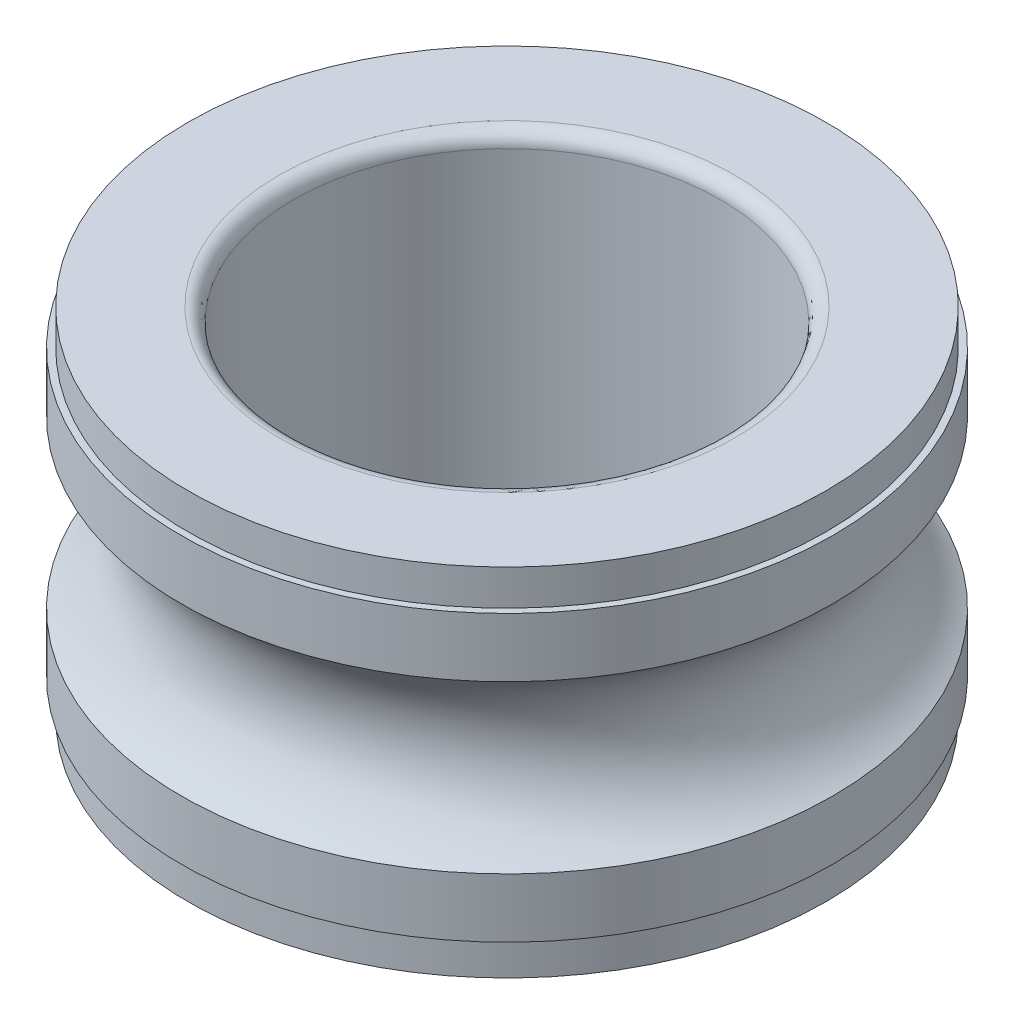
from build123d import *


with BuildPart() as part:
    # Sketch1 → Revolve1 (revolve)
    with BuildSketch(Plane(origin=(0, 0, 0), x_dir=(-1, 0, 0), z_dir=(0, 0, -1))):
        with BuildLine():
            Line((-4.575, -0.5), (-4.575, -1.330865705))
            ThreePointArc((-4.575, -1.330865705), (-3.9, -2.5), (-4.575, -3.669134295))
            Line((-4.575, -3.669134295), (-4.575, -4.5))
            Line((-4.575, -4.5), (-4.4835, -4.5))
            Line((-4.4835, -4.5), (-4.4835, -5))
            Line((-4.4835, -5), (-3.2, -5))
            ThreePointArc((-3.2, -5), (-3.058578644, -4.941421356), (-3, -4.8))
            Line((-3, -4.8), (-3, -0.2))
            ThreePointArc((-3, -0.2), (-3.058578644, -0.058578644), (-3.2, 0))
            Line((-3.2, 0), (-4.4835, 0))
            Line((-4.4835, 0), (-4.4835, -0.5))
            Line((-4.4835, -0.5), (-4.575, -0.5))
        make_face()
    revolve(axis=Axis((0, -5.003495744, 0), (0, 1, 0)))


solid = part.part
